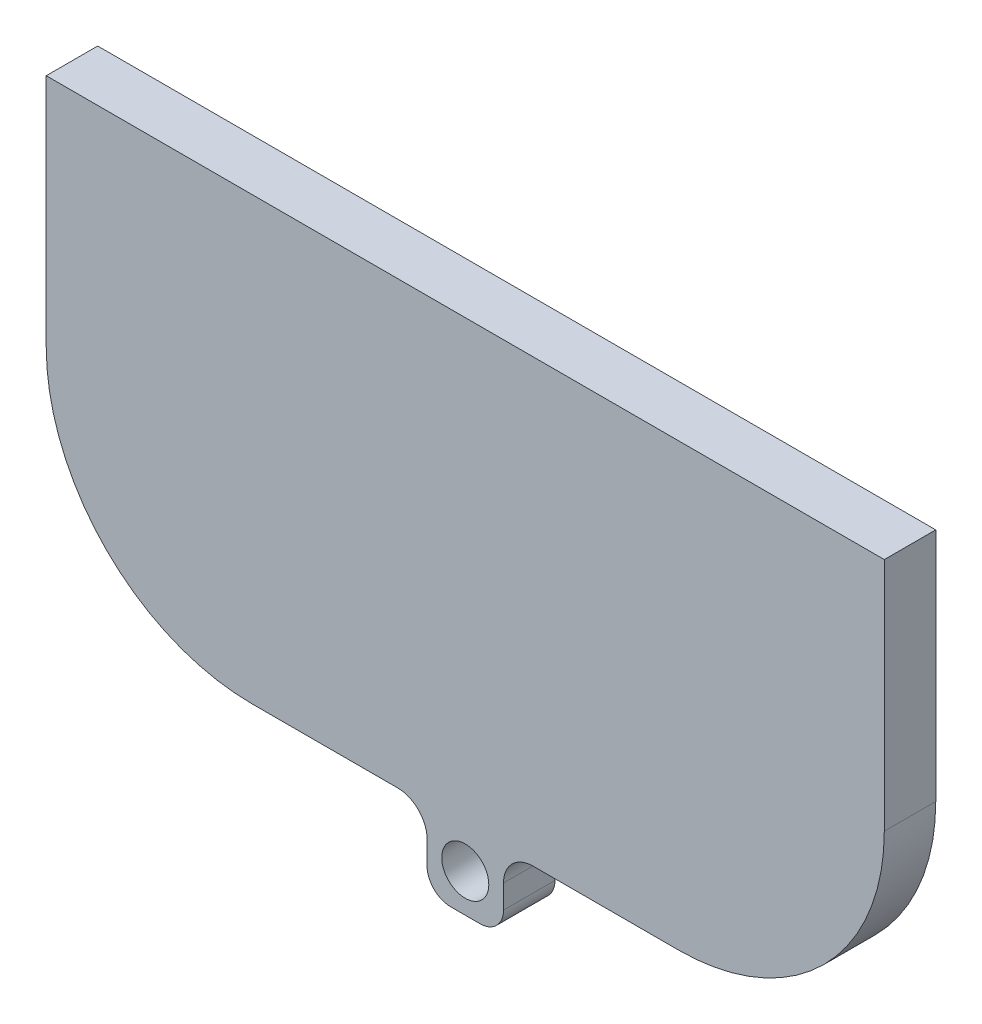
from build123d import *

# Parameters (mm, degrees)
BOSS_EXTRUDE1_DEPTH = 3.5
SKETCH2_R           = 1.6
BOSS_EXTRUDE2_DEPTH = 3.5
FILLET1_R           = 2


with BuildPart() as part:
    # Sketch1 → Boss-Extrude1 (new body)
    with BuildSketch(Plane.XY):
        with BuildLine():
            Line((-24.5, 0), (24.5, 0))
            Line((24.5, 0), (28.5, 0))
            Line((28.5, 0), (28.5, -16))
            ThreePointArc((28.5, -16), (24.399494937, -25.899494937), (14.5, -30))
            Line((14.5, -30), (-14.5, -30))
            ThreePointArc((-14.5, -30), (-24.399494937, -25.899494937), (-28.5, -16))
            Line((-28.5, -16), (-28.5, 0))
            Line((-28.5, 0), (-24.5, 0))
        make_face()
    extrude(amount=BOSS_EXTRUDE1_DEPTH)

    # Sketch2 → Boss-Extrude2 (add)
    with BuildSketch(Plane.XY.offset(3.5)):
        with BuildLine():
            Line((2.6, -30), (-2.6, -30))
            Line((-2.6, -30), (-2.6, -33.6))
            ThreePointArc((-2.6, -33.6), (-2.13137085, -34.73137085), (-1, -35.2))
            Line((-1, -35.2), (1, -35.2))
            ThreePointArc((1, -35.2), (2.13137085, -34.73137085), (2.6, -33.6))
            Line((2.6, -33.6), (2.6, -30))
        make_face()
        with Locations((0, -32.6)):
            Circle(SKETCH2_R, mode=Mode.SUBTRACT)
    extrude(amount=-BOSS_EXTRUDE2_DEPTH)

    # Fillet1
    fillet1_edges = [part.edges().sort_by_distance(p)[0] for p in [
        (2.6, -30, 1.75),
        (-2.6, -30, 1.75),
    ]]
    fillet(fillet1_edges, radius=FILLET1_R)


solid = part.part
